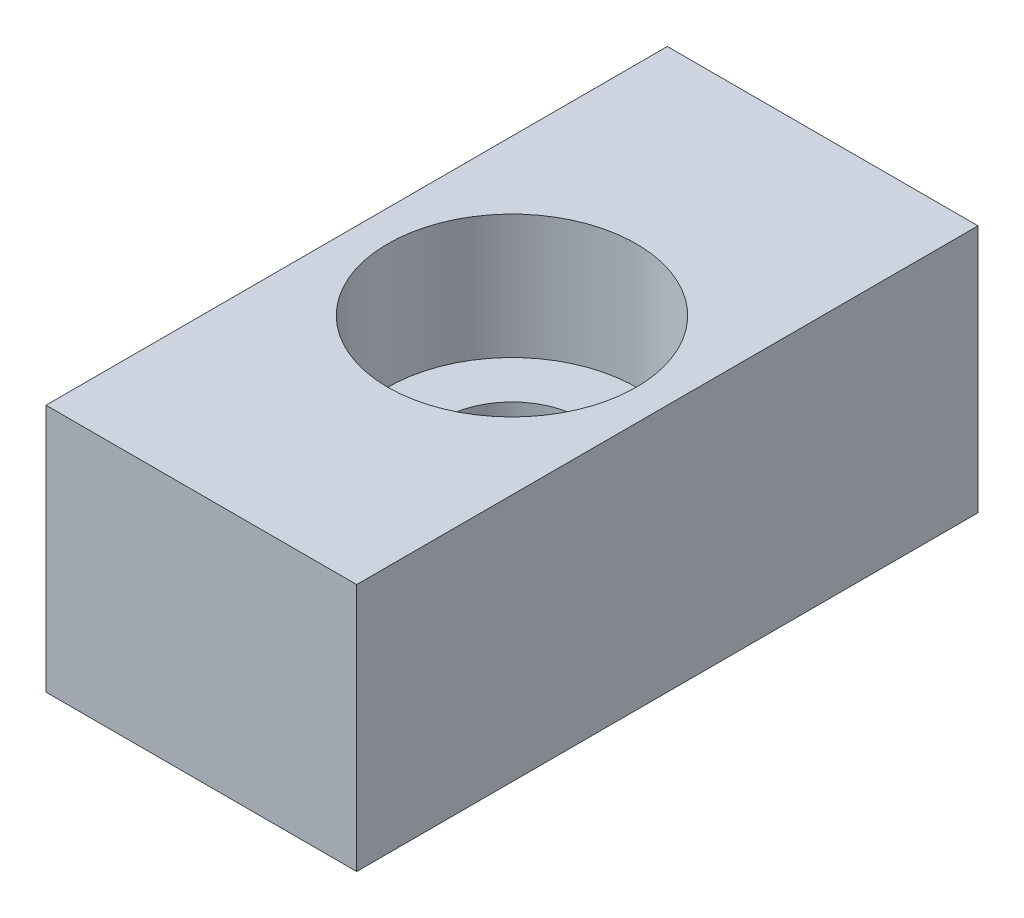
from build123d import *

# Parameters (mm, degrees)
SKETCH1_W           = 10
SKETCH1_H           = 20
SKETCH1_R           = 2.25
BOSS_EXTRUDE1_DEPTH = 4
SKETCH2_W           = 10
SKETCH2_H           = 20
SKETCH2_R           = 4
BOSS_EXTRUDE2_DEPTH = 4


with BuildPart() as part:
    # Sketch1 → Boss-Extrude1 (new body)
    with BuildSketch(Plane(origin=(0, 0, 0), x_dir=(1, 0, 0), z_dir=(0, 1, 0))):
        Rectangle(SKETCH1_W, SKETCH1_H)
        Circle(SKETCH1_R, mode=Mode.SUBTRACT)
    extrude(amount=BOSS_EXTRUDE1_DEPTH)

    # Sketch2 → Boss-Extrude2 (add)
    with BuildSketch(Plane(origin=(0, 4, 0), x_dir=(1, 0, 0), z_dir=(0, 1, 0))):
        Rectangle(SKETCH2_W, SKETCH2_H)
        Circle(SKETCH2_R, mode=Mode.SUBTRACT)
    extrude(amount=BOSS_EXTRUDE2_DEPTH)


solid = part.part
